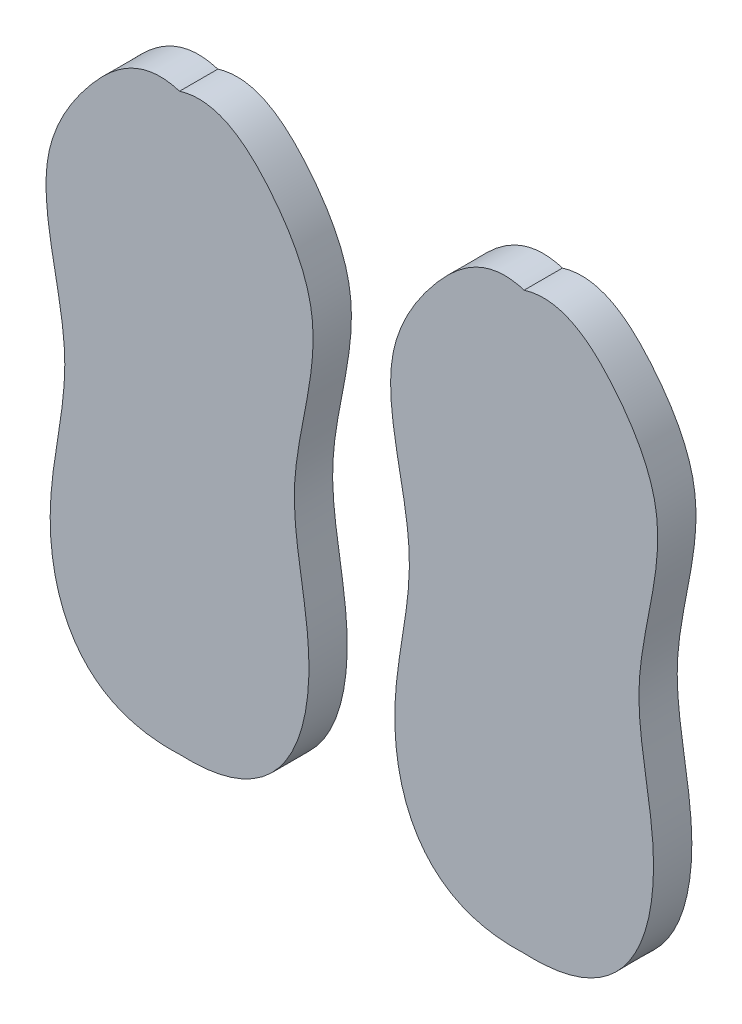
from build123d import *

# Parameters (mm, degrees)
BOSS_EXTRUDE1_DEPTH = 10


with BuildPart() as part:
    # Sketch2 → Boss-Extrude1 (new body)
    with BuildSketch(Plane.XY):
        with BuildLine():
            add(Edge.make_bspline(
                [(0, 99.183285394), (9.940064442, 102.262299521), (24.122612265, 90.46414584), (40.33453266, 61.943212567), (25.180027607, 26.436288764), (39.04722634, -17.717188406), (27.280230095, -52.099061458), (0, -50.816714606)],
                knots=[0, 0, 0, 0, 0.146529274, 0.268876507, 0.503259797, 0.694010191, 1, 1, 1, 1], degree=3))
            add(Edge.make_bspline(
                [(0, 99.183285394), (-9.940064442, 102.262299521), (-24.122612265, 90.46414584), (-40.33453266, 61.943212567), (-25.180027607, 26.436288764), (-39.04722634, -17.717188406), (-27.280230095, -52.099061458), (0, -50.816714606)],
                knots=[0, 0, 0, 0, 0.146529274, 0.268876507, 0.503259797, 0.694010191, 1, 1, 1, 1], degree=3))
        make_face()
    extrude(amount=BOSS_EXTRUDE1_DEPTH)


with BuildPart() as body_2:
    # Mirror2: mirrored copy
    add(part.part.mirror(Plane(origin=(45, 0, 0), x_dir=(0, 0, 1), z_dir=(1, 0, 0))))


solid = Compound([part.part, body_2.part])
